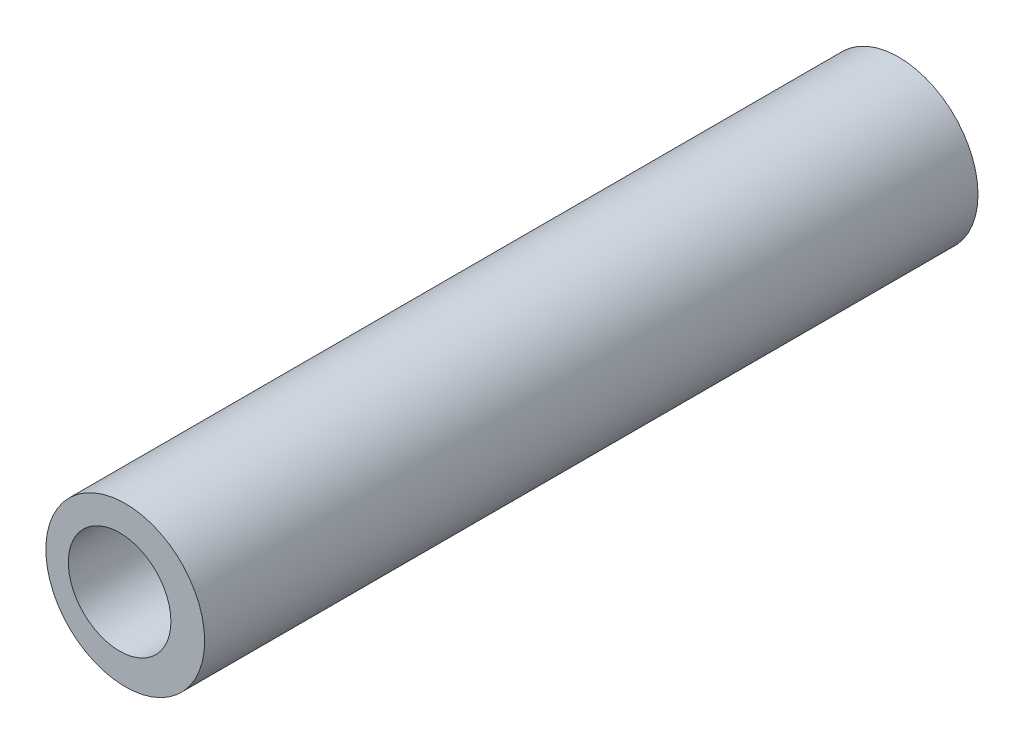
from build123d import *

# Parameters (mm, degrees)
SKETCH2_R           = 84.71174294
SKETCH2_R_2         = 54.720953129
BOSS_EXTRUDE2_DEPTH = 825


with BuildPart() as part:
    # Sketch2 → Boss-Extrude2 (new body)
    with BuildSketch(Plane.XY):
        Circle(SKETCH2_R)
        with Locations((-6.012276889, 0)):
            Circle(SKETCH2_R_2, mode=Mode.SUBTRACT)
    extrude(amount=BOSS_EXTRUDE2_DEPTH)


solid = part.part
